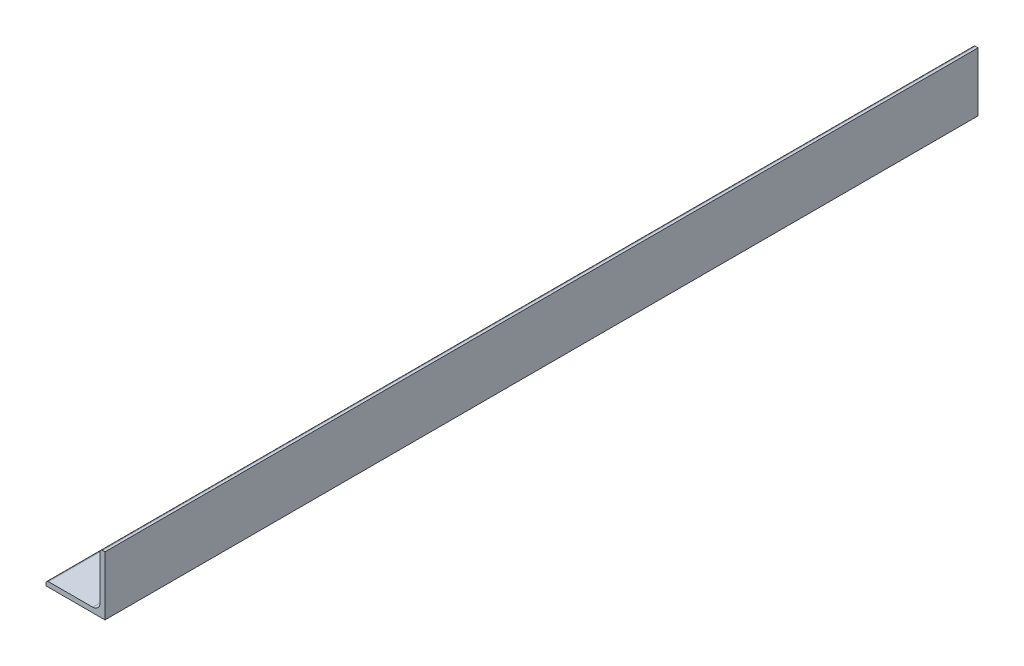
from build123d import *

# Parameters (mm, degrees)
BOSS_EXTRUDE1_DEPTH = 609.6
SKETCH3_W           = 635.2
SKETCH3_H           = 38.1
CUT_EXTRUDE1_DEPTH  = 60
SKETCH4_W           = 20
SKETCH4_H           = 38.1
CUT_EXTRUDE2_DEPTH  = 60


with BuildPart() as part:
    # Sketch2 → Boss-Extrude1 (new, symmetric)
    with BuildSketch(Plane.XY):
        with BuildLine():
            Line((-19.05, -19.05), (19.05, -19.05))
            Line((19.05, -19.05), (19.05, 19.05))
            Line((19.05, 19.05), (17.4625, 19.05))
            ThreePointArc((17.4625, 19.05), (16.339967985, 18.585032015), (15.875, 17.4625))
            Line((15.875, 17.4625), (15.875, -11.0998))
            ThreePointArc((15.875, -11.0998), (14.476376302, -14.476376302), (11.0998, -15.875))
            Line((11.0998, -15.875), (-17.4625, -15.875))
            ThreePointArc((-17.4625, -15.875), (-18.585032015, -16.339967985), (-19.05, -17.4625))
            Line((-19.05, -17.4625), (-19.05, -19.05))
        make_face()
    extrude(amount=BOSS_EXTRUDE1_DEPTH, both=True)

    # Sketch3 → Cut-Extrude1 (cut)
    with BuildSketch(Plane(origin=(19.05, 0, 0), x_dir=(0, 0, -1), z_dir=(1, 0, 0))):
        with Locations((292, 0)):
            Rectangle(SKETCH3_W, SKETCH3_H)
    extrude(amount=-CUT_EXTRUDE1_DEPTH, mode=Mode.SUBTRACT)

    # Sketch4 → Cut-Extrude2 (cut)
    with BuildSketch(Plane(origin=(19.05, 0, 0), x_dir=(0, 0, -1), z_dir=(1, 0, 0))):
        with Locations((-35.6, 0)):
            Rectangle(SKETCH4_W, SKETCH4_H)
    extrude(amount=-CUT_EXTRUDE2_DEPTH, mode=Mode.SUBTRACT)


solid = part.part
